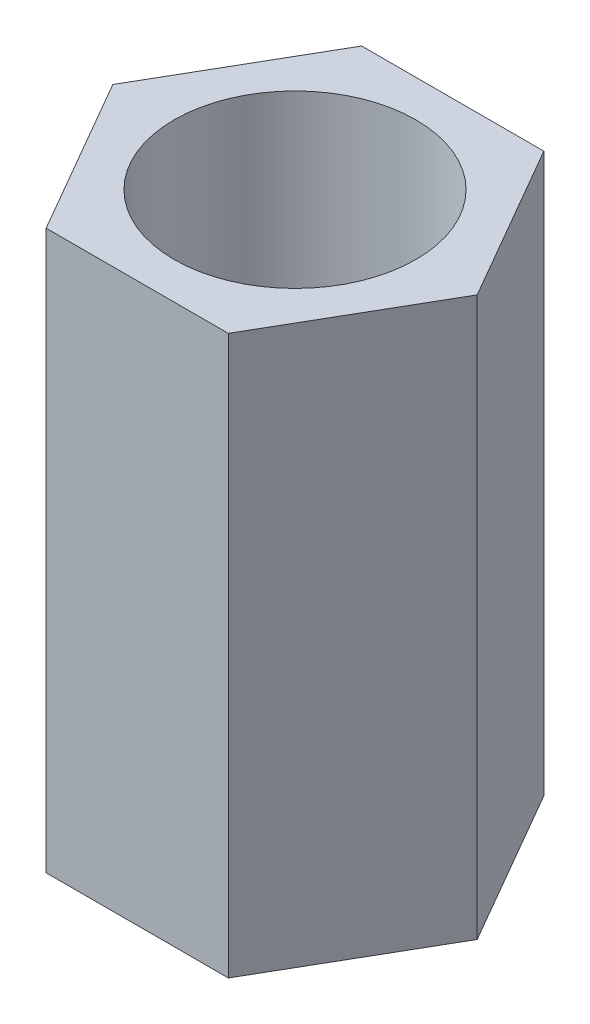
from build123d import *

# Parameters (mm, degrees)
SKETCH1_R           = 1.3
BOSS_EXTRUDE1_DEPTH = 6


with BuildPart() as part:
    # Sketch1 → Boss-Extrude1 (new body)
    with BuildSketch(Plane(origin=(0, 0, 0), x_dir=(1, 0, 0), z_dir=(0, 1, 0))):
        Polygon((0.979018569, -1.695709904), (1.958037139, 0), (0.979018569, 1.695709904), (-0.979018569, 1.695709904), (-1.958037139, 0), (-0.979018569, -1.695709904), align=None)
        Circle(SKETCH1_R, mode=Mode.SUBTRACT)
    extrude(amount=BOSS_EXTRUDE1_DEPTH)


solid = part.part
